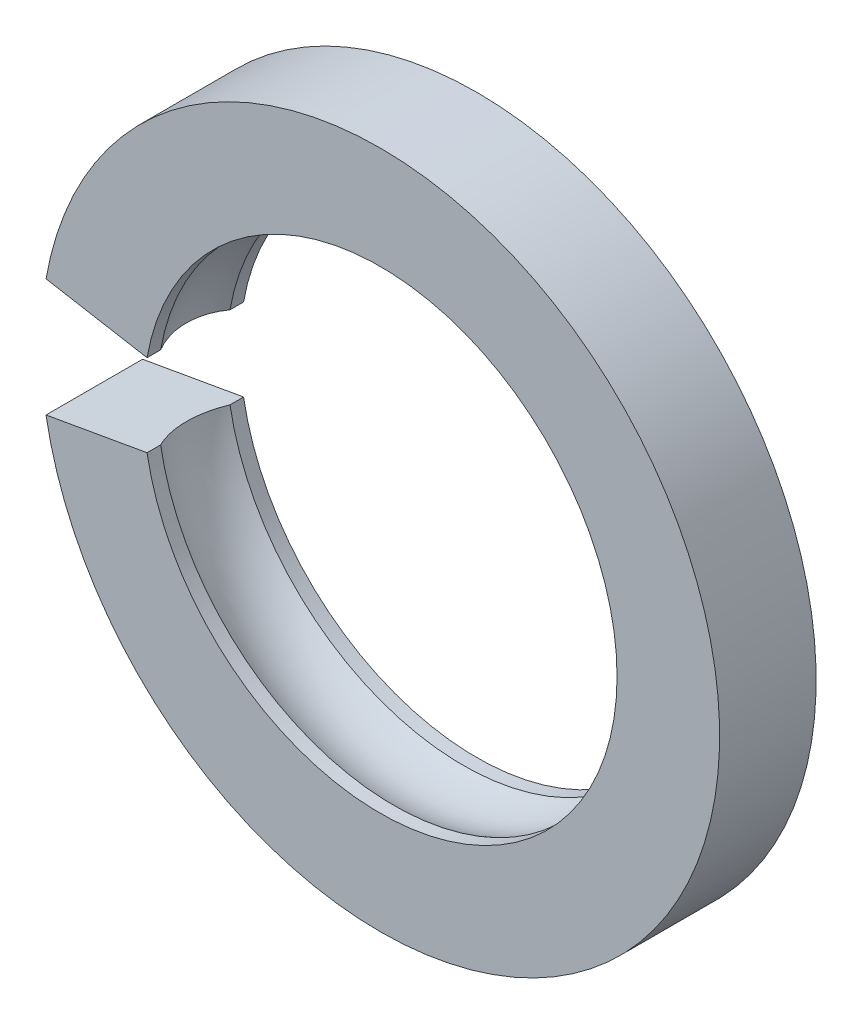
from build123d import *

# Parameters (mm, degrees)
SKETCH1_R           = 22.5
SKETCH1_R_2         = 15.7
BOSS_EXTRUDE1_DEPTH = 6.4
CUT_EXTRUDE1_DEPTH  = 33.457048541


with BuildPart() as part:
    # Sketch1 → Boss-Extrude1 (new body)
    with BuildSketch(Plane.XY):
        Circle(SKETCH1_R)
        Circle(SKETCH1_R_2, mode=Mode.SUBTRACT)
    extrude(amount=BOSS_EXTRUDE1_DEPTH)

    # Sketch2 → Cut-Extrude1 (cut, through all)
    with BuildSketch(Plane.XY):
        Polygon((0, 0), (-29.645546143, 5.227309643), (-29.645546143, -5.227309643), align=None)
    extrude(amount=CUT_EXTRUDE1_DEPTH, mode=Mode.SUBTRACT)

    # Sketch5 → Cut-Revolve1 (revolve, cut)
    with BuildSketch(Plane(origin=(0, 0, 0), x_dir=(-0.984807753012197, 0.1736481776669938, 0), z_dir=(-0.1736481776669938, -0.984807753012197, 0))):
        with BuildLine():
            Line((15.7, -0.9), (15.7, -5.5))
            ThreePointArc((15.7, -5.5), (16.301238658, -3.2), (15.7, -0.9))
        make_face()
    revolve(axis=Axis((0, 0, -0.32), (0, 0, 1)), mode=Mode.SUBTRACT)


solid = part.part
